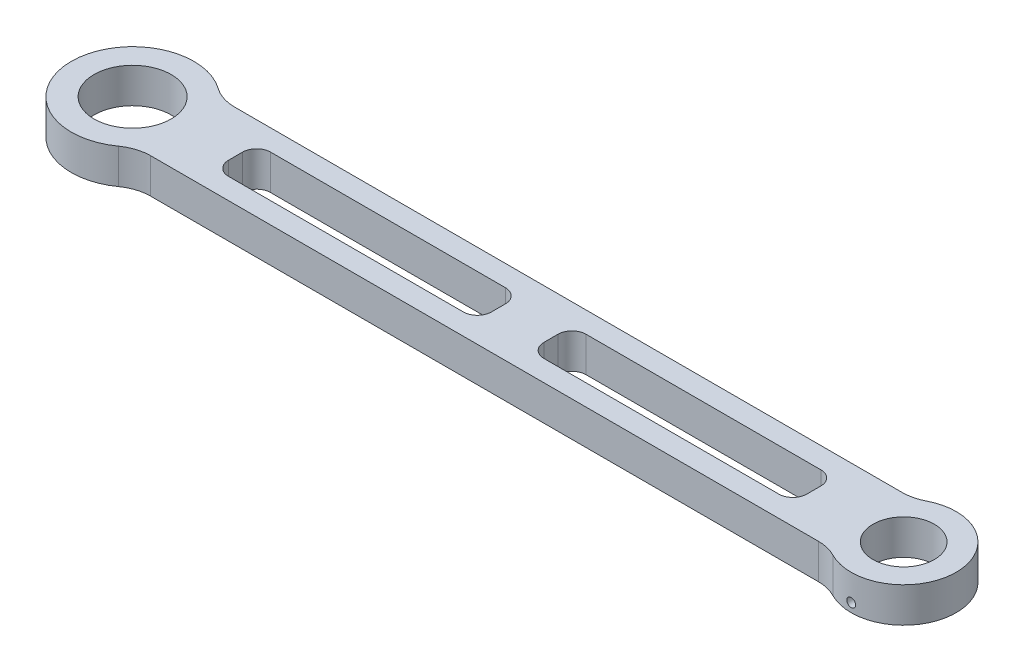
from build123d import *

# Parameters (mm, degrees)
SKETCH1_W           = 75
SKETCH1_H           = 12
SKETCH1_R           = 17.5
SKETCH1_R_2         = 11
SKETCH1_R_3         = 15
SKETCH1_R_4         = 8.75
BOSS_EXTRUDE1_DEPTH = 10
FILLET1_R           = 4
FILLET2_R           = 12
SKETCH2_R           = 1.25
CUT_EXTRUDE1_DEPTH  = 9


with BuildPart() as part:
    # Sketch1 → Boss-Extrude1 (new body)
    with BuildSketch(Plane(origin=(0, 0, 0), x_dir=(1, 0, 0), z_dir=(0, 1, 0))):
        with BuildLine():
            Line((211, 12), (12.737739203, 12))
            ThreePointArc((12.737739203, 12), (16.265921985, 6.45521355), (17.5, 0))
            ThreePointArc((17.5, 0), (16.265921985, -6.45521355), (12.737739203, -12))
            Line((12.737739203, -12), (211, -12))
            ThreePointArc((211, -12), (205, 0), (211, 12))
        make_face()
        with Locations((66.868869601, 0)):
            Rectangle(SKETCH1_W, SKETCH1_H, mode=Mode.SUBTRACT)
        with Locations((156.868869601, 0)):
            Rectangle(SKETCH1_W, SKETCH1_H, mode=Mode.SUBTRACT)
        Circle(SKETCH1_R)
        Circle(SKETCH1_R_2, mode=Mode.SUBTRACT)
        with Locations((220, 0)):
            Circle(SKETCH1_R_3)
        with Locations((220, 0)):
            Circle(SKETCH1_R_4, mode=Mode.SUBTRACT)
    extrude(amount=BOSS_EXTRUDE1_DEPTH)

    # Fillet1
    fillet1_edges = [part.edges().sort_by_distance(p)[0] for p in [
        (119.368869601, 5, -6),
        (119.368869601, 5, 6),
        (194.368869601, 5, 6),
        (194.368869601, 5, -6),
        (29.368869601, 5, -6),
        (29.368869601, 5, 6),
        (104.368869601, 5, 6),
        (104.368869601, 5, -6),
    ]]
    fillet(fillet1_edges, radius=FILLET1_R)

    # Fillet2
    fillet2_edges = [part.edges().sort_by_distance(p)[0] for p in [
        (12.737739203, 5, 12),
        (12.737739203, 5, -12),
        (211, 5, -12),
        (211, 5, 12),
    ]]
    fillet(fillet2_edges, radius=FILLET2_R)

    # Sketch2 → Cut-Extrude1 (cut, symmetric)
    with BuildSketch(Plane.XY.offset(12)):
        with Locations((220, 2.5)):
            Circle(SKETCH2_R)
    extrude(amount=CUT_EXTRUDE1_DEPTH, both=True, mode=Mode.SUBTRACT)


solid = part.part
